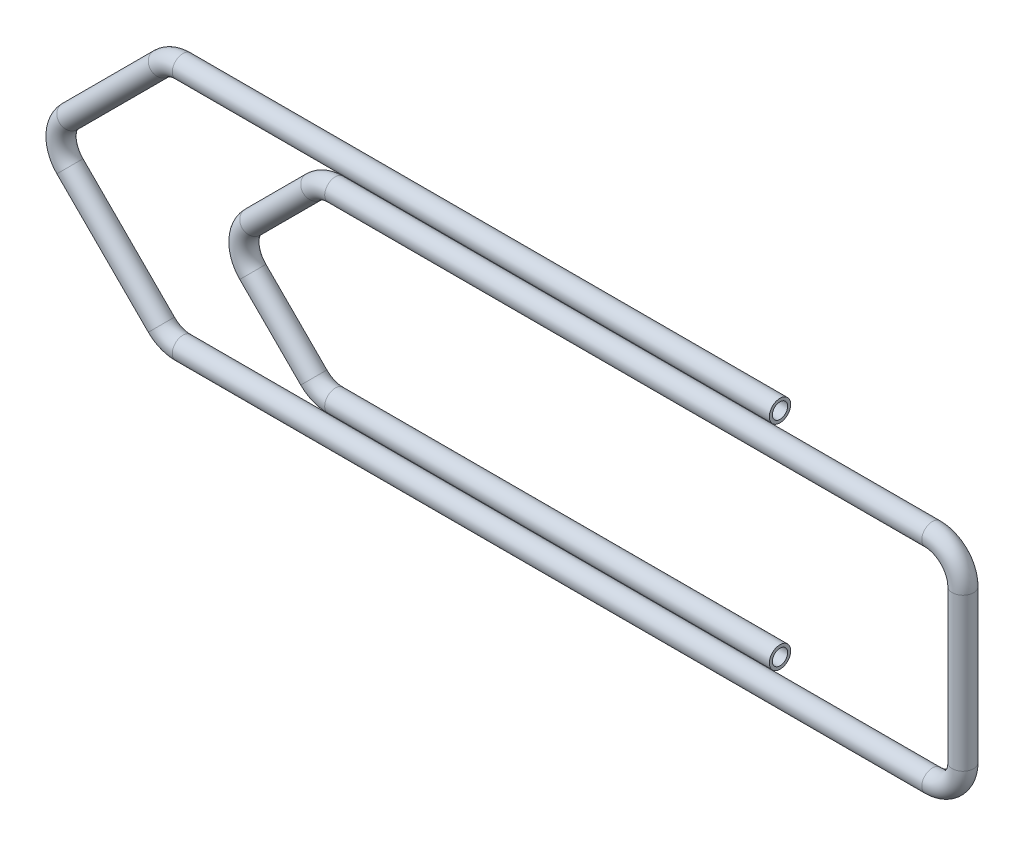
from build123d import *

# Parameters (mm, degrees)
SKICA2_R     = 0.35
SKO_EPINA1_T = -0.1


with BuildPart() as part:
    # Táhnout po křivce1: sweep along a path in Skica1
    with BuildLine(Plane.XY) as t_hnout_po_k_ivce1_path:
        Line((0, 0), (-19.585786438, 0))
        ThreePointArc((-19.585786438, 0), (-19.96846987, -0.076120467), (-20.292893219, -0.292893219))
        Line((-20.292893219, -0.292893219), (-23.292893219, -3.292893219))
        ThreePointArc((-23.292893219, -3.292893219), (-23.585786438, -4), (-23.292893219, -4.707106781))
        Line((-23.292893219, -4.707106781), (-20.292893219, -7.707106781))
        ThreePointArc((-20.292893219, -7.707106781), (-19.96846987, -7.923879533), (-19.585786438, -8))
        Line((-19.585786438, -8), (5, -8))
        ThreePointArc((5, -8), (5.707106781, -7.707106781), (6, -7))
        Line((6, -7), (6, -2))
        ThreePointArc((6, -2), (5.707106781, -1.292893219), (5, -1))
        Line((5, -1), (-14.585786438, -1))
        ThreePointArc((-14.585786438, -1), (-14.96846987, -1.076120467), (-15.292893219, -1.292893219))
        Line((-15.292893219, -1.292893219), (-17.292893219, -3.292893219))
        ThreePointArc((-17.292893219, -3.292893219), (-17.585786438, -4), (-17.292893219, -4.707106781))
        Line((-17.292893219, -4.707106781), (-15.292893219, -6.707106781))
        ThreePointArc((-15.292893219, -6.707106781), (-14.96846987, -6.923879533), (-14.585786438, -7))
        Line((-14.585786438, -7), (0, -7))
    # Skica2 → Táhnout po křivce1 (sweep)
    with BuildSketch(Plane(origin=(0, 0, 0), x_dir=(0, 0, -1), z_dir=(1, 0, 0))):
        Circle(SKICA2_R)
    sweep(path=t_hnout_po_k_ivce1_path.line)

    # Skořepina1
    sko_epina1_openings = [part.faces().sort_by_distance(p)[0] for p in [
        (0, -7, 0),
        (0, 0, 0),
    ]]
    offset(amount=SKO_EPINA1_T, openings=sko_epina1_openings, kind=Kind.INTERSECTION)


solid = part.part
